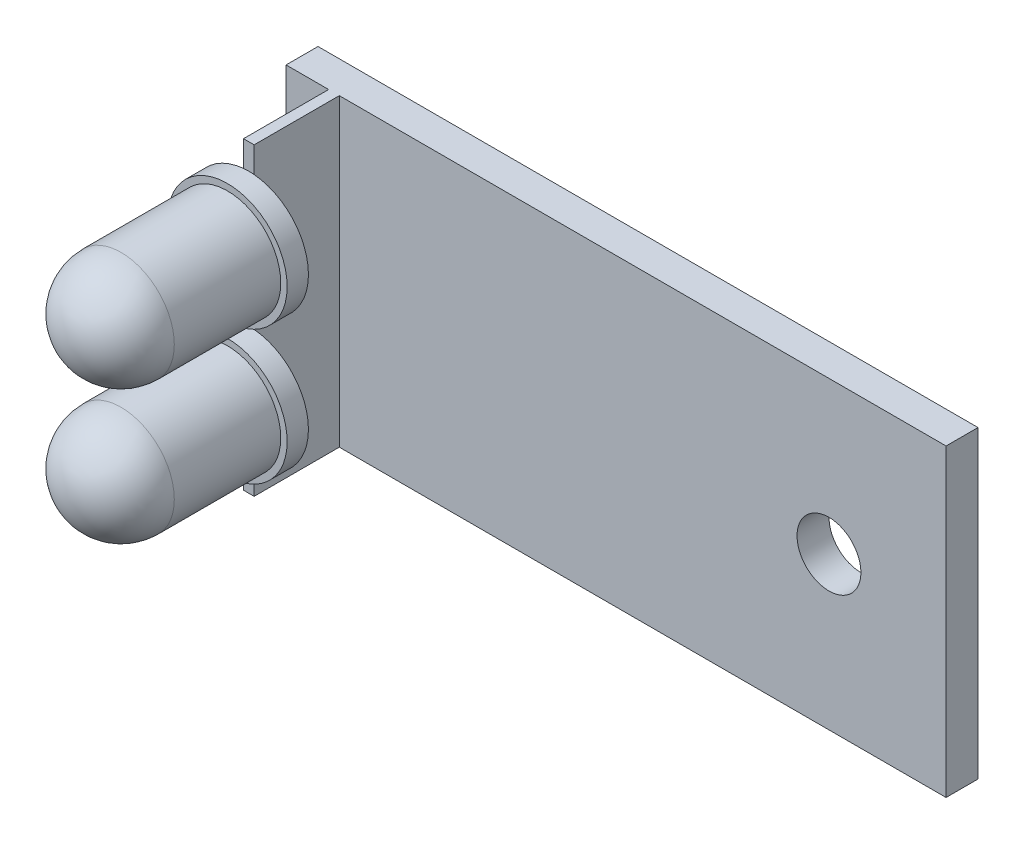
from build123d import *

# Parameters (mm, degrees)
SKETCH1_W           = 31
SKETCH1_H           = 14.3
BOSS_EXTRUDE1_DEPTH = 1.5
SKETCH2_W           = 0.5
SKETCH2_H           = 4
BOSS_EXTRUDE2_DEPTH = 14.3
SKETCH5_R           = 1.5
CUT_EXTRUDE1_DEPTH  = 1.5


with BuildPart() as part:
    # Sketch1 → Boss-Extrude1 (new body)
    with BuildSketch(Plane.XY):
        with Locations((15.5, 0)):
            Rectangle(SKETCH1_W, SKETCH1_H)
    extrude(amount=BOSS_EXTRUDE1_DEPTH)

    # Sketch2 → Boss-Extrude2 (add, through all)
    with BuildSketch(Plane.XZ.offset(7.15)):
        with Locations((2.25, 3.5)):
            Rectangle(SKETCH2_W, SKETCH2_H)
    extrude(amount=-BOSS_EXTRUDE2_DEPTH)

    # Sketch4 → Revolve1 (revolve)
    with BuildSketch(Plane.XZ.offset(3.15)):
        with BuildLine():
            Line((2.25, 14), (2.25, 5.5))
            Line((2.25, 5.5), (5.05, 5.5))
            Line((5.05, 5.5), (5.05, 6.5))
            Line((5.05, 6.5), (4.75, 6.5))
            Line((4.75, 6.5), (4.75, 11.499998492))
            ThreePointArc((4.75, 11.499998492), (4.017767486, 13.26776642), (2.25, 14))
        make_face()
    revolve1 = revolve(axis=Axis((2.25, -3.15, 14), (0, 0, -1)))

    # Mirror1: Revolve1 across plane
    add(revolve1.mirror(Plane.ZX))

    # Sketch5 → Cut-Extrude1 (cut)
    with BuildSketch(Plane.XY.offset(1.5)):
        with Locations((25.5, 0)):
            Circle(SKETCH5_R)
    extrude(amount=-CUT_EXTRUDE1_DEPTH, mode=Mode.SUBTRACT)


solid = part.part
